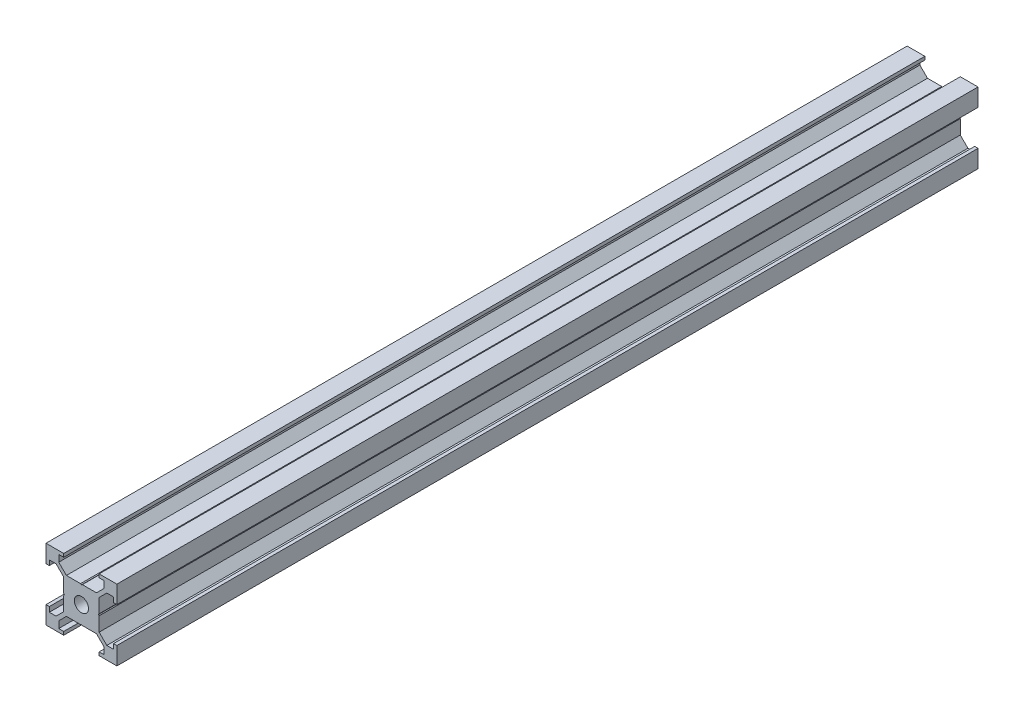
from build123d import *

# Parameters (mm, degrees)
SKETCH1_R           = 2
BOSS_EXTRUDE1_DEPTH = 243


with BuildPart() as part:
    # Sketch1 → Boss-Extrude1 (new body)
    with BuildSketch(Plane.XY):
        Polygon((6.4, 7.156263811), (4.243736189, 5), (5, 5), (5, 4.243736189), (7.156263811, 6.4), (9.056263811, 6.4), (9.056263811, 5), (10, 5), (10, 10), (5, 10), (5, 9.056263811), (6.4, 9.056263811), align=None)
        Polygon((-5, 0.245745613), (-5, 5), (-0.245745613, 5), (0, 4.827927069), (0.245745613, 5), (5, 5), (5, 0.245745613), (4.827927069, 0), (5, -0.245745613), (5, -5), (0.245745613, -5), (0, -4.827927069), (-0.245745613, -5), (-5, -5), (-5, -0.245745613), (-4.827927069, 0), align=None)
        Circle(SKETCH1_R, mode=Mode.SUBTRACT)
        Polygon((-10, 10), (-10, 5), (-9.056263811, 5), (-9.056263811, 6.4), (-7.156263811, 6.4), (-5, 4.243736189), (-5, 5), (-4.243736189, 5), (-6.4, 7.156263811), (-6.4, 9.056263811), (-5, 9.056263811), (-5, 10), align=None)
        Polygon((-5, -5), (-5, -4.243736189), (-7.156263811, -6.4), (-9.056263811, -6.4), (-9.056263811, -5), (-10, -5), (-10, -10), (-5, -10), (-5, -9.056263811), (-6.4, -9.056263811), (-6.4, -7.156263811), (-4.243736189, -5), align=None)
        Polygon((5, -5), (4.243736189, -5), (6.4, -7.156263811), (6.4, -9.056263811), (5, -9.056263811), (5, -10), (10, -10), (10, -5), (9.056263811, -5), (9.056263811, -6.4), (7.156263811, -6.4), (5, -4.243736189), align=None)
    extrude(amount=BOSS_EXTRUDE1_DEPTH)


solid = part.part
